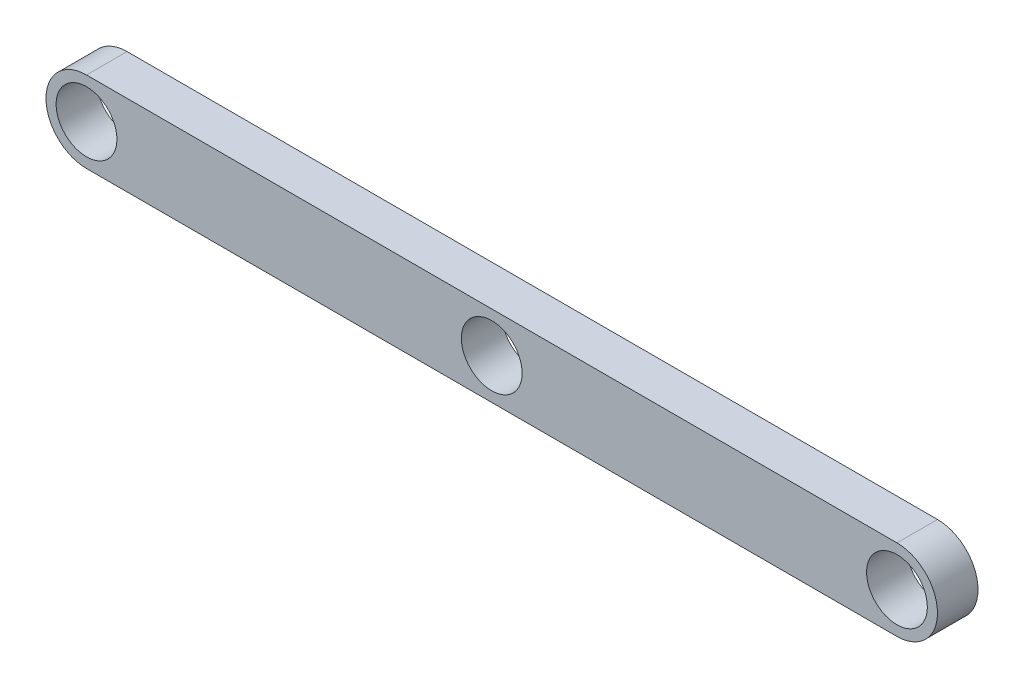
from build123d import *

# Parameters (mm, degrees)
BOSS_EXTRUDE1_DEPTH            = 6.35
F_4_0_375_DIAMETER_HOLE1_D     = 9.525
F_4_0_375_DIAMETER_HOLE1_DEPTH = 6.35


with BuildPart() as part:
    # Sketch1 → Boss-Extrude1 (new body)
    with BuildSketch(Plane.XY):
        with BuildLine():
            Line((-63.5, -6.35), (63.5, -6.35))
            ThreePointArc((63.5, -6.35), (69.85, 0), (63.5, 6.35))
            Line((63.5, 6.35), (-63.5, 6.35))
            ThreePointArc((-63.5, 6.35), (-69.85, 0), (-63.5, -6.35))
        make_face()
    extrude(amount=BOSS_EXTRUDE1_DEPTH)

    # #4 (0.375) Diameter Hole1
    with Locations(Plane.XY.offset(6.35)):
        with Locations((0, 0), (-63.5, 0), (63.5, 0)):
            Hole(F_4_0_375_DIAMETER_HOLE1_D / 2, depth=F_4_0_375_DIAMETER_HOLE1_DEPTH)


solid = part.part
